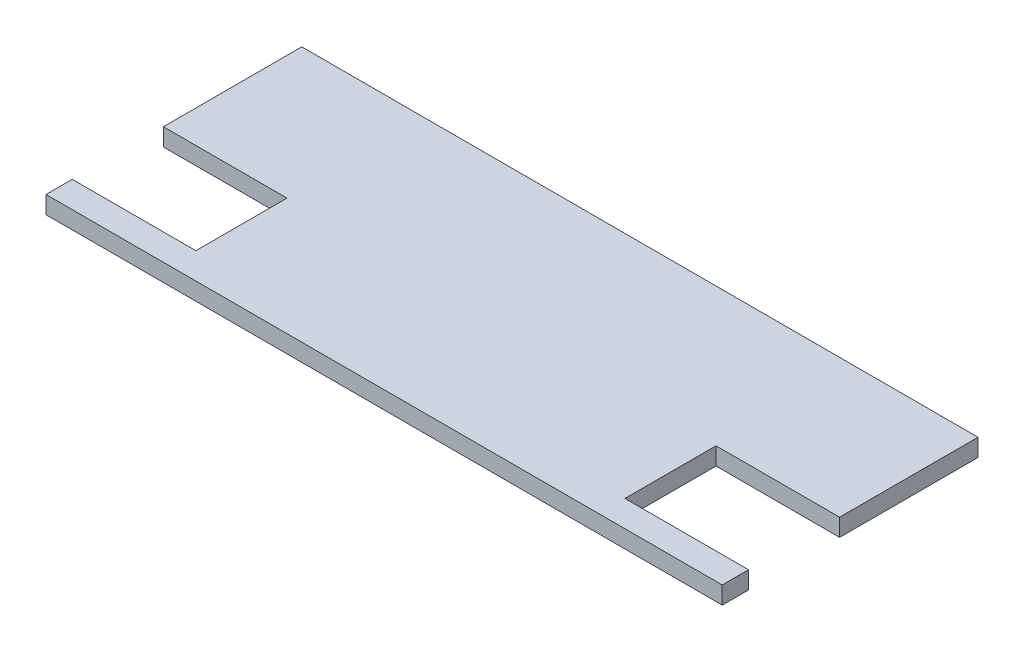
from build123d import *

# Parameters (mm, degrees)
SALIENTE_EXTRUIR1_DEPTH = 5


with BuildPart() as part:
    # Croquis1 → Saliente-Extruir1 (new body)
    with BuildSketch(Plane(origin=(0, 0, 0), x_dir=(1, 0, 0), z_dir=(0, 1, 0))):
        Polygon((-96.5, -29), (-96.5, -36.5), (96.5, -36.5), (96.5, -29), (61.23, -29), (61.23, -3), (96.5, -3), (96.5, 36.5), (-96.5, 36.5), (-96.5, -3), (-61.23, -3), (-61.23, -29), align=None)
    extrude(amount=SALIENTE_EXTRUIR1_DEPTH)


solid = part.part
